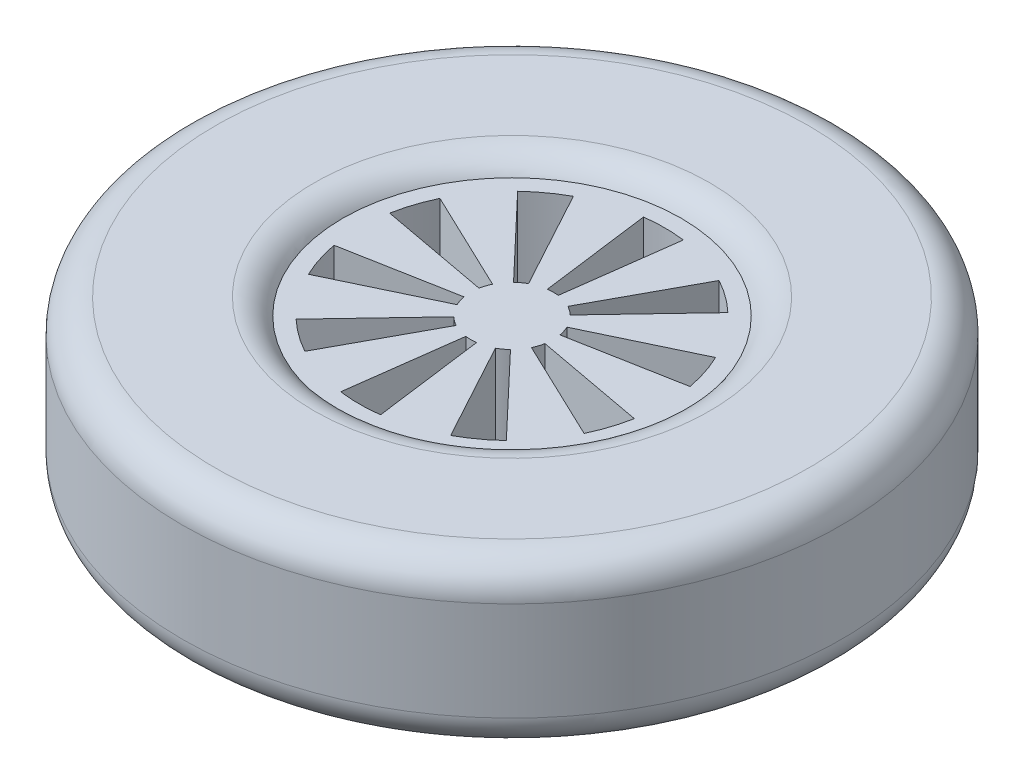
from build123d import *

# Parameters (mm, degrees)
SKETCH2_W                = 50
SKETCH2_H                = 50
FILLET2_R                = 10
SKETCH3_R                = 60
BOSS_EXTRUDE2_DEPTH      = 20
BOSS_EXTRUDE2_DEPTH_BACK = 20
CUT_EXTRUDE1_DEPTH       = 46
CIRPATTERN1_COUNT        = 10


with BuildPart() as part:
    # Sketch2 → Revolve1 (revolve)
    with BuildSketch(Plane.XY):
        with Locations((-75, 0)):
            Rectangle(SKETCH2_W, SKETCH2_H)
    revolve(axis=Axis((0, 0, 0), (0, 1, 0)))

    # Fillet2
    fillet2_edges = [part.edges().sort_by_distance(p)[0] for p in [
        (50, 25, 0),
        (100, 25, 0),
        (100, -25, 0),
        (50, -25, 0),
    ]]
    fillet(fillet2_edges, radius=FILLET2_R)

    # Sketch3 → Boss-Extrude2 (add, two sides)
    with BuildSketch(Plane(origin=(0, 0, 0), x_dir=(1, 0, 0), z_dir=(0, 1, 0))) as boss_extrude2_sk:
        Circle(SKETCH3_R)
    extrude(amount=BOSS_EXTRUDE2_DEPTH)
    extrude(boss_extrude2_sk.sketch, amount=-BOSS_EXTRUDE2_DEPTH_BACK)

    # Sketch4 → Cut-Extrude1 (cut, through all)
    with BuildSketch(Plane.XZ.offset(20)):
        with BuildLine():
            ThreePointArc((-1.631577403, 12.393060767), (0, 12.5), (1.631577403, 12.393060767))
            Line((1.631577403, 12.393060767), (6.048550589, 45.943303012))
            ThreePointArc((6.048550589, 45.943303012), (0, 46.339745962), (-6.048550589, 45.943303012))
            Line((-6.048550589, 45.943303012), (-1.631577403, 12.393060767))
        make_face()
    cut_extrude1 = extrude(amount=-CUT_EXTRUDE1_DEPTH, mode=Mode.SUBTRACT)

    # CirPattern1: Cut-Extrude1 ×10 about axis
    cirpattern1_axis = Axis((0, 0, 0), (0, 1, 0))
    for i in range(1, CIRPATTERN1_COUNT):
        add(cut_extrude1.rotate(cirpattern1_axis, i * 360 / CIRPATTERN1_COUNT), mode=Mode.SUBTRACT)


solid = part.part
